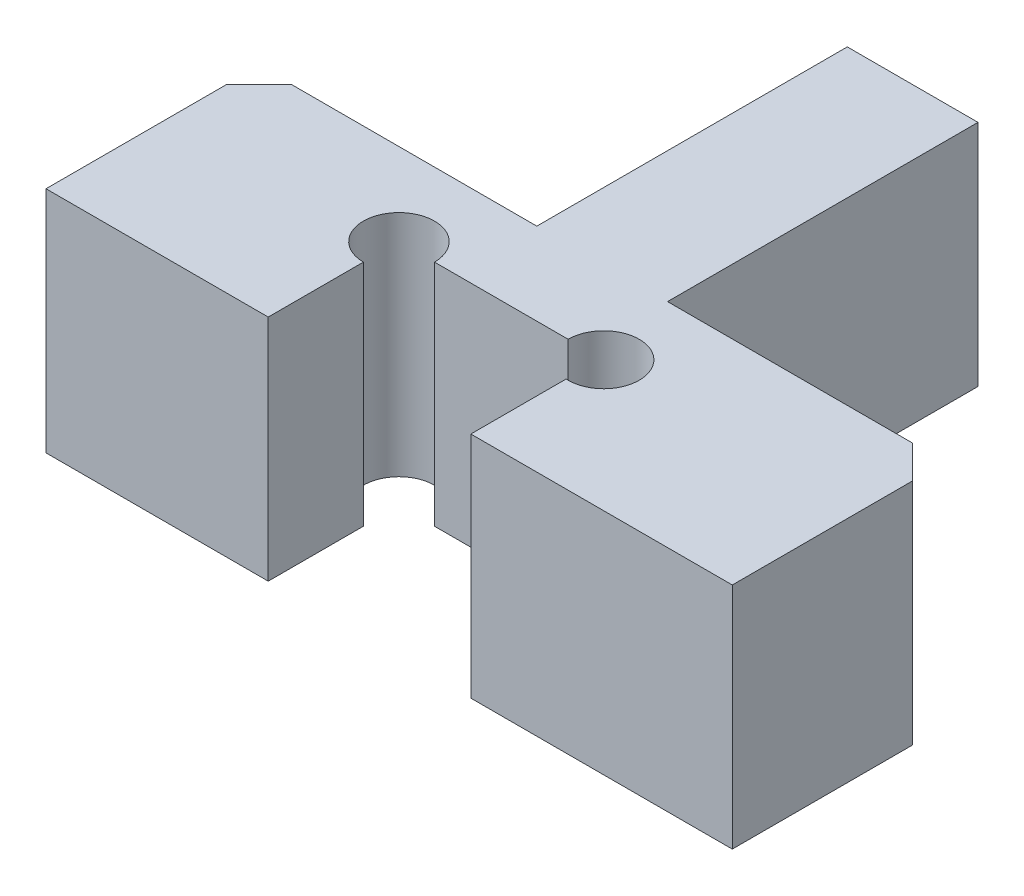
from build123d import *

# Parameters (mm, degrees)
BOSS_EXTRUDE1_DEPTH = 3.5
CHAMFER1_SIZE       = 0.5


with BuildPart() as part:
    # Sketch1 → Boss-Extrude1 (new body)
    with BuildSketch(Plane(origin=(0, 0, 0), x_dir=(1, 0, 0), z_dir=(0, 1, 0))):
        with BuildLine():
            Line((-5.25, -0.51424544), (-1.85, -0.51424544))
            Line((-1.85, -0.51424544), (-1.85, 0.942004129))
            ThreePointArc((-1.85, 0.942004129), (-2.234489618, 1.870244178), (-1.306249568, 1.48575456))
            Line((-1.306249568, 1.48575456), (0.738401898, 1.48575456))
            ThreePointArc((0.738401898, 1.48575456), (1.677846262, 1.85870341), (1.25, 0.942955555))
            Line((1.25, 0.942955555), (1.25, -0.51424544))
            Line((1.25, -0.51424544), (5.25, -0.51424544))
            Line((5.25, -0.51424544), (5.25, 2.74500456))
            Line((5.25, 2.74500456), (1, 2.74500456))
            Line((1, 2.74500456), (1, 7.49500456))
            Line((1, 7.49500456), (-1, 7.49500456))
            Line((-1, 7.49500456), (-1, 2.74500456))
            Line((-1, 2.74500456), (-5.25, 2.74500456))
            Line((-5.25, 2.74500456), (-5.25, -0.51424544))
        make_face()
    extrude(amount=BOSS_EXTRUDE1_DEPTH)

    # Chamfer1
    chamfer1_edges = [part.edges().sort_by_distance(p)[0] for p in [
        (5.25, 1.75, -2.74500456),
        (-5.25, 1.75, -2.74500456),
    ]]
    chamfer(chamfer1_edges, length=CHAMFER1_SIZE)


solid = part.part
